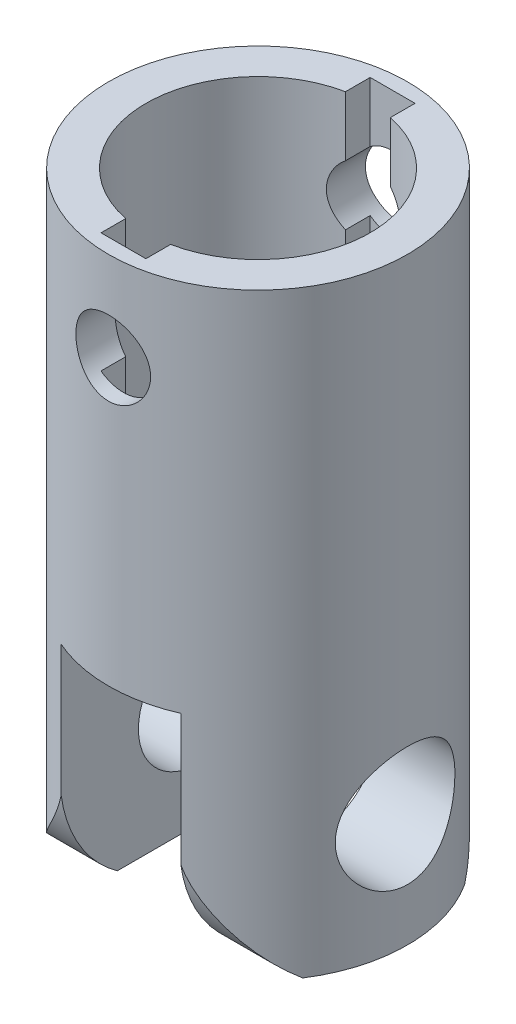
from build123d import *
from build123d.topology import SkipClean

# Parameters (mm, degrees)
SKETCH1_R               = 10
BOSS_EXTRUDE1_DEPTH     = 25
BOSS_EXTRUDE2_START     = -15
BOSS_EXTRUDE2_DEPTH     = 15
CUT_EXTRUDE2_DEPTH      = 20
CUT_EXTRUDE2_DEPTH_BACK = 20
SKETCH4_R               = 4
SKETCH5_R               = 7.5
CUT_EXTRUDE3_DEPTH      = 20
CUT_EXTRUDE4_DEPTH      = 10
CUT_EXTRUDE4_DEPTH_BACK = 10
SKETCH6_R               = 2.5
SKETCH7_W               = 3
SKETCH7_H               = 18
CUT_EXTRUDE5_DEPTH      = 20


with BuildPart() as part:
    # Sketch1 → Boss-Extrude1 (new body)
    with BuildSketch(Plane(origin=(0, 0, 0), x_dir=(1, 0, 0), z_dir=(0, 1, 0))):
        Circle(SKETCH1_R)
    extrude(amount=BOSS_EXTRUDE1_DEPTH)

    # Sketch3 → Boss-Extrude2 (add)
    with SkipClean():  # the faces are left unmerged after this step: merging them gives an invalid solid
        with BuildSketch(Plane(origin=(0, 0, 0), x_dir=(1, 0, 0), z_dir=(0, 1, 0)).offset(BOSS_EXTRUDE2_START)):
            with BuildLine():
                Line((-4, 9.16515139), (-4, -9.16515139))
                ThreePointArc((-4, -9.16515139), (-10, 0), (-4, 9.16515139))
            make_face()
            with BuildLine():
                Line((4, 9.16515139), (4, -9.16515139))
                ThreePointArc((4, -9.16515139), (10, 0), (4, 9.16515139))
            make_face()
        extrude(amount=BOSS_EXTRUDE2_DEPTH)

    # Sketch4 → Cut-Extrude2 (cut, two sides: drawn at the far end of the back side and taken through both)
    with SkipClean():  # the faces are left unmerged after this step: merging them gives an invalid solid
        with BuildSketch(Plane(origin=(0, 0, 0), x_dir=(0, 0, -1), z_dir=(1, 0, 0)).offset(-CUT_EXTRUDE2_DEPTH_BACK)):
            with Locations((0, -7.5)):
                Circle(SKETCH4_R)
            with BuildLine():
                Line((9.25, -7.5), (14.844368797, -7.5))
                Line((14.844368797, -7.5), (14.844368797, -20.157267439))
                Line((14.844368797, -20.157267439), (-15.402777655, -20.157267439))
                Line((-15.402777655, -20.157267439), (-15.402777655, -7.5))
                Line((-15.402777655, -7.5), (-9.25, -7.5))
                ThreePointArc((-9.25, -7.5), (0, -16.75), (9.25, -7.5))
            make_face()
        extrude(amount=CUT_EXTRUDE2_DEPTH + CUT_EXTRUDE2_DEPTH_BACK, mode=Mode.SUBTRACT)

    # Sketch5 → Cut-Extrude3 (cut)
    with SkipClean():  # the faces are left unmerged after this step: merging them gives an invalid solid
        with BuildSketch(Plane(origin=(0, 25, 0), x_dir=(1, 0, 0), z_dir=(0, 1, 0))):
            Circle(SKETCH5_R)
        extrude(amount=-CUT_EXTRUDE3_DEPTH, mode=Mode.SUBTRACT)

    # Sketch6 → Cut-Extrude4 (cut, two sides: drawn at the far end of the back side and taken through both)
    with SkipClean():  # the faces are left unmerged after this step: merging them gives an invalid solid
        with BuildSketch(Plane.XY.offset(-CUT_EXTRUDE4_DEPTH_BACK)):
            with Locations((0, 19)):
                Circle(SKETCH6_R)
        extrude(amount=CUT_EXTRUDE4_DEPTH + CUT_EXTRUDE4_DEPTH_BACK, mode=Mode.SUBTRACT)

    # Sketch7 → Cut-Extrude5 (cut)
    with SkipClean():  # the faces are left unmerged after this step: merging them gives an invalid solid
        with BuildSketch(Plane(origin=(0, 25, 0), x_dir=(1, 0, 0), z_dir=(0, 1, 0))):
            Rectangle(SKETCH7_W, SKETCH7_H)
        extrude(amount=-CUT_EXTRUDE5_DEPTH, mode=Mode.SUBTRACT)


solid = part.part
